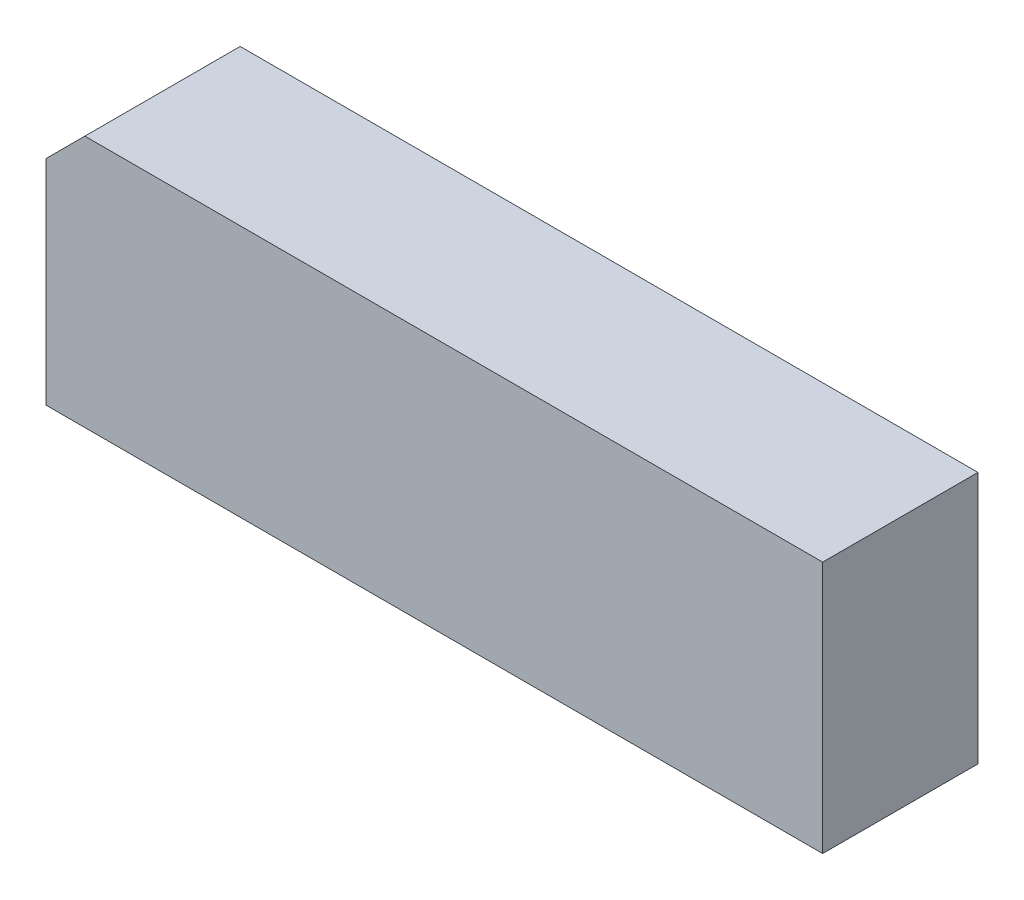
from build123d import *

# Parameters (mm, degrees)
AUFSATZ_LINEAR_AUSTRAGEN1_DEPTH = 4


with BuildPart() as part:
    # Skizze1 → Aufsatz-Linear austragen1 (new body)
    with BuildSketch(Plane.XY):
        Polygon((0, 5.5), (1, 6.5), (20, 6.5), (20, 0), (0, 0), align=None)
    extrude(amount=AUFSATZ_LINEAR_AUSTRAGEN1_DEPTH)


solid = part.part
